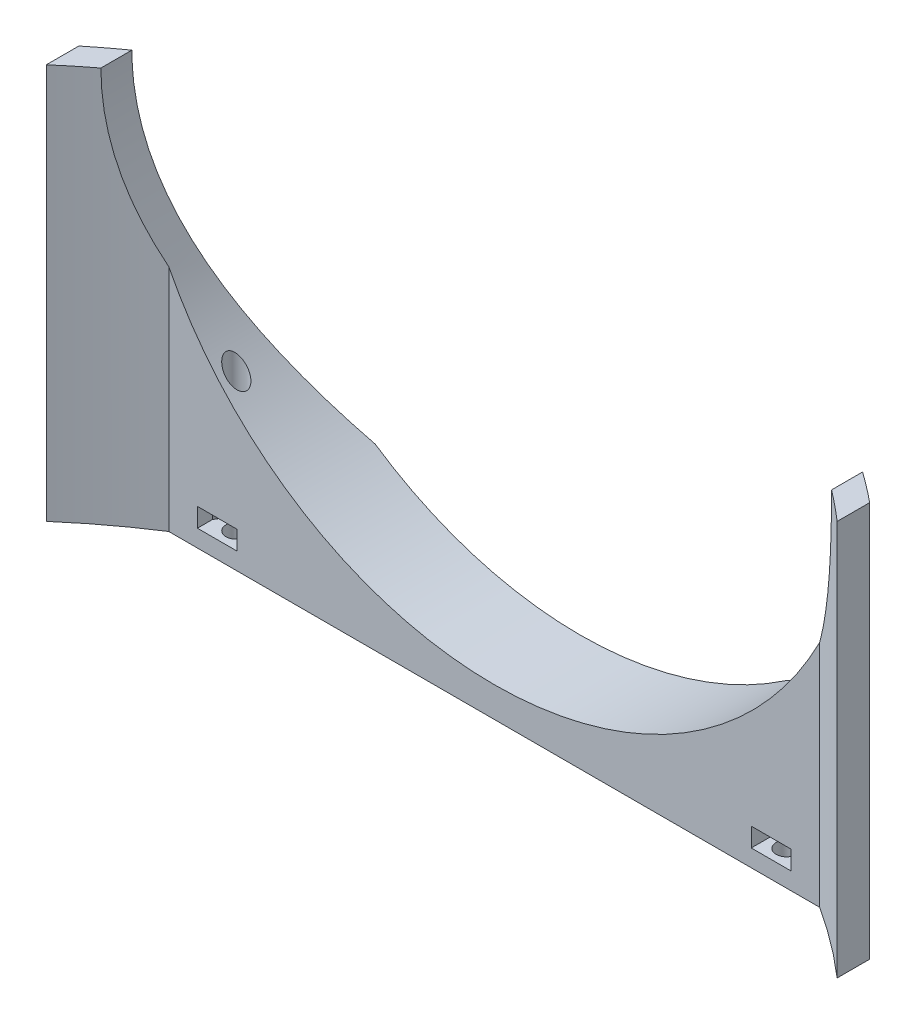
from build123d import *

# Parameters (mm, degrees)
SKETCH1_W           = 92
SKETCH1_H           = 31
BOSS_EXTRUDE1_DEPTH = 46
SKETCH2_R           = 103
SKETCH2_R_2         = 73
CUT_EXTRUDE1_DEPTH  = 47
SKETCH7_R           = 1.2
CUT_EXTRUDE5_DEPTH  = 47
CUT_EXTRUDE2_DEPTH  = 47
SKETCH5_R           = 42.5
CUT_EXTRUDE4_DEPTH  = 17.103780853
CUT_EXTRUDE6_START  = -2
CUT_EXTRUDE6_DEPTH  = 2.2


with BuildPart() as part:
    # Sketch1 → Boss-Extrude1 (new body)
    with BuildSketch(Plane(origin=(0, 0, 0), x_dir=(1, 0, 0), z_dir=(0, 1, 0))):
        Rectangle(SKETCH1_W, SKETCH1_H)
    extrude(amount=BOSS_EXTRUDE1_DEPTH)

    # Sketch2 → Cut-Extrude1 (cut, through all)
    with BuildSketch(Plane(origin=(0, 46, 0), x_dir=(1, 0, 0), z_dir=(0, 1, 0))):
        with Locations((0, -53.5)):
            Circle(SKETCH2_R)
        with Locations((0, -53.5)):
            Circle(SKETCH2_R_2, mode=Mode.SUBTRACT)
    extrude(amount=-CUT_EXTRUDE1_DEPTH, mode=Mode.SUBTRACT)

    # Sketch7 → Cut-Extrude5 (cut, through all)
    with BuildSketch(Plane.XZ):
        with Locations((-32, -7.5)):
            Circle(SKETCH7_R)
        with Locations((32, -7.5)):
            Circle(SKETCH7_R)
    extrude(amount=-CUT_EXTRUDE5_DEPTH, mode=Mode.SUBTRACT)

    # Sketch3 → Cut-Extrude2 (cut, through all)
    with BuildSketch(Plane(origin=(0, 46, 0), x_dir=(1, 0, 0), z_dir=(0, 1, 0))):
        with BuildLine():
            Line((-37.855118544, 5.5), (37.855118544, 5.5))
            ThreePointArc((37.855118544, 5.5), (0, -123.6), (-37.855118544, 5.5))
        make_face()
    extrude(amount=-CUT_EXTRUDE2_DEPTH, mode=Mode.SUBTRACT)

    # Sketch5 → Cut-Extrude4 (cut, through all)
    with BuildSketch(Plane(origin=(0, 0, -15.5), x_dir=(-1, 0, 0), z_dir=(0, 0, -1))):
        with Locations((0, 46)):
            Circle(SKETCH5_R)
    extrude(amount=-CUT_EXTRUDE4_DEPTH, mode=Mode.SUBTRACT)

    # Sketch8 → Cut-Extrude6 (cut)
    with BuildSketch(Plane.XZ.offset(CUT_EXTRUDE6_START)):
        Polygon((-34.523561667, -7.229062977), (-33.183568052, -9.55), (-30.816431948, -9.55), (-29.904759513, -7.970937023), (-29.904759513, -4.97225781), (-34.523561667, -4.97225781), align=None)
        Polygon((29.904759513, -4.97225781), (29.904759513, -7.970937023), (30.816431948, -9.55), (33.183568052, -9.55), (34.523561667, -7.229062977), (34.523561667, -4.97225781), align=None)
    extrude(amount=-CUT_EXTRUDE6_DEPTH, mode=Mode.SUBTRACT)


solid = part.part
